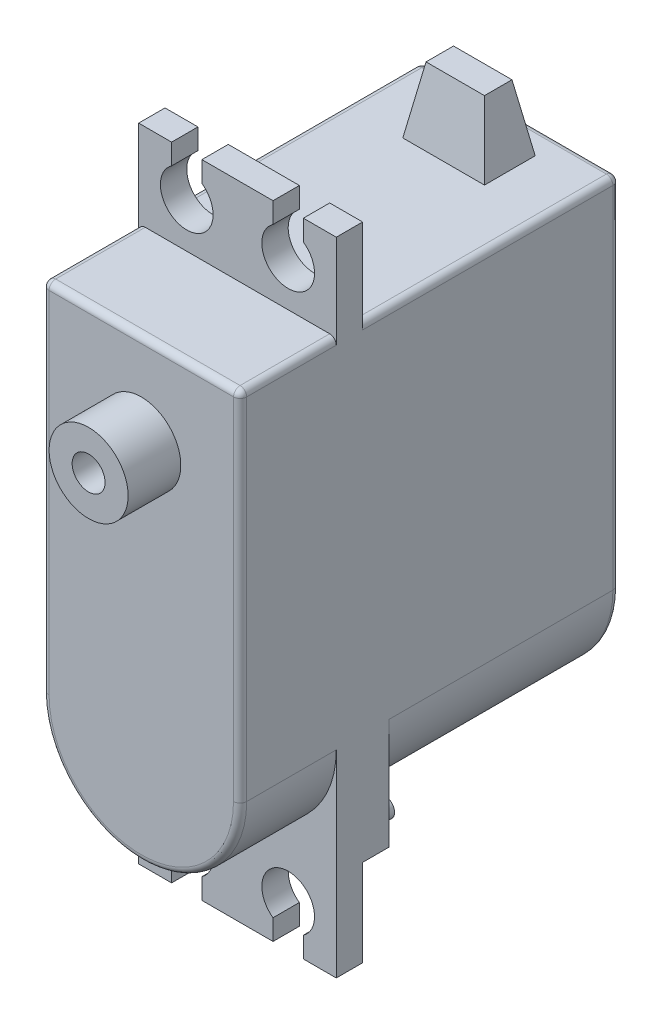
from build123d import *

# Parameters (mm, degrees)
BOSS_EXTRUDE1_DEPTH     = 28.8
SKETCH3_R               = 3
SKETCH3_R_2             = 1.25
BOSS_EXTRUDE2_DEPTH     = 4
BOSS_EXTRUDE3_DEPTH     = 7.5
SKETCH5_W               = 15
SKETCH5_H               = 13.170644239
BOSS_EXTRUDE4_DEPTH     = 2
SKETCH6_R               = 0.725
BOSS_EXTRUDE5_DEPTH     = 1
CUT_EXTRUDE1_DEPTH      = 5
CUT_EXTRUDE1_DEPTH_BACK = 29.8
SKETCH8_W               = 6.2
SKETCH8_H               = 3.85
BOSS_EXTRUDE6_DEPTH     = 5
BOSS_EXTRUDE6_TAPER     = 10
FILLET1_R               = 0.5


with BuildPart() as part:
    # Sketch2 → Boss-Extrude1 (new body)
    with BuildSketch(Plane.XY):
        with BuildLine():
            Line((-7.5, 7), (7.5, 7))
            Line((7.5, 7), (7.5, -20.1))
            ThreePointArc((7.5, -20.1), (0, -27.6), (-7.5, -20.1))
            Line((-7.5, -20.1), (-7.5, 7))
        make_face()
    extrude(amount=-BOSS_EXTRUDE1_DEPTH)

    # Sketch3 → Boss-Extrude2 (add)
    with BuildSketch(Plane.XY):
        Circle(SKETCH3_R)
        Circle(SKETCH3_R_2, mode=Mode.SUBTRACT)
    extrude(amount=BOSS_EXTRUDE2_DEPTH)

    # Sketch4 → Boss-Extrude3 (add, symmetric)
    with BuildSketch(Plane(origin=(0, 0, 0), x_dir=(0, 0, -1), z_dir=(1, 0, 0))):
        Polygon((7.3, 7), (7.3, 13.6), (9.3, 13.6), (9.3, 7), (9.3, -35.1), (7.3, -35.1), align=None)
    extrude(amount=BOSS_EXTRUDE3_DEPTH, both=True)

    # Sketch5 → Boss-Extrude4 (add)
    with BuildSketch(Plane(origin=(0, 0, -9.3), x_dir=(-1, 0, 0), z_dir=(0, 0, -1))):
        with Locations((0, -21.914677881)):
            Rectangle(SKETCH5_W, SKETCH5_H)
    extrude(amount=BOSS_EXTRUDE4_DEPTH)

    # Sketch6 → Boss-Extrude5 (add)
    with BuildSketch(Plane(origin=(0, 0, -11.3), x_dir=(-1, 0, 0), z_dir=(0, 0, -1))):
        with Locations((-6.2, -27)):
            Circle(SKETCH6_R)
        with Locations((6.2, -27)):
            Circle(SKETCH6_R)
    extrude(amount=BOSS_EXTRUDE5_DEPTH)

    # Sketch7 → Cut-Extrude1 (cut, two sides)
    with BuildSketch(Plane.XY) as cut_extrude1_sk:
        with BuildLine():
            Line((-5, 12.036306817), (-5, 13.6))
            Line((-5, 13.6), (-2.7, 13.6))
            Line((-2.7, 13.6), (-2.7, 12.036306817))
            ThreePointArc((-2.7, 12.036306817), (-3.85, 8.4), (-5, 12.036306817))
        make_face()
        with BuildLine():
            Line((2.7, 13.6), (2.7, 12.036306817))
            ThreePointArc((2.7, 12.036306817), (3.85, 8.4), (5, 12.036306817))
            Line((5, 12.036306817), (5, 13.6))
            Line((5, 13.6), (2.7, 13.6))
        make_face()
        with BuildLine():
            Line((5, -33.536306817), (5, -35.1))
            Line((5, -35.1), (2.7, -35.1))
            Line((2.7, -35.1), (2.7, -33.536306817))
            ThreePointArc((2.7, -33.536306817), (3.85, -29.9), (5, -33.536306817))
        make_face()
        with BuildLine():
            Line((-2.7, -35.1), (-2.7, -33.536306817))
            ThreePointArc((-2.7, -33.536306817), (-3.85, -29.9), (-5, -33.536306817))
            Line((-5, -33.536306817), (-5, -35.1))
            Line((-5, -35.1), (-2.7, -35.1))
        make_face()
    extrude(amount=CUT_EXTRUDE1_DEPTH, mode=Mode.SUBTRACT)
    extrude(cut_extrude1_sk.sketch, amount=-CUT_EXTRUDE1_DEPTH_BACK, mode=Mode.SUBTRACT)

    # Sketch8 → Boss-Extrude6 (add)
    with BuildSketch(Plane(origin=(0, 7, 0), x_dir=(1, 0, 0), z_dir=(0, 1, 0))):
        with Locations((0, 24.875)):
            Rectangle(SKETCH8_W, SKETCH8_H)
    extrude(amount=BOSS_EXTRUDE6_DEPTH, taper=BOSS_EXTRUDE6_TAPER)

    # Fillet1
    fillet1_edges = [part.edges().sort_by_distance(p)[0] for p in [
        (-7.5, -6.55, -28.8),
        (0, -27.6, -28.8),
        (7.5, 7, -3.65),
        (-7.5, 7, -3.65),
        (7.5, -6.55, -28.8),
        (0, -27.6, 0),
        (-7.5, -6.55, 0),
        (0, 7, 0),
        (7.5, -6.55, 0),
        (0, 7, -28.8),
        (-7.5, 7, -19.05),
        (7.5, 7, -19.05),
    ]]
    fillet(fillet1_edges, radius=FILLET1_R)


solid = part.part
